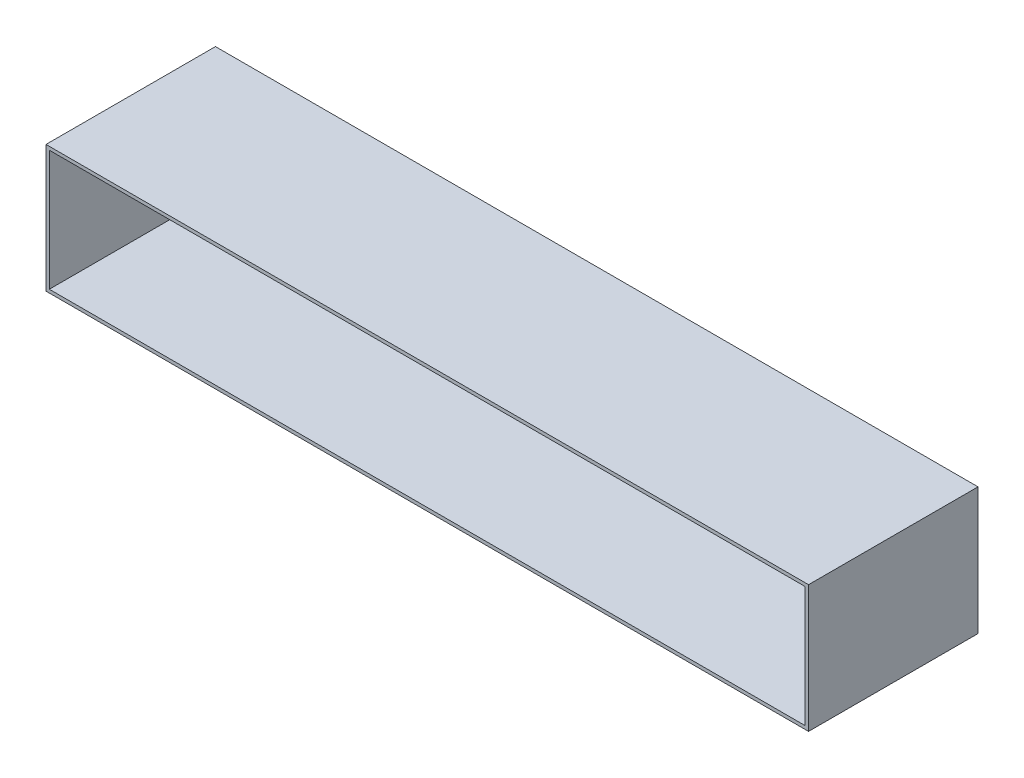
from build123d import *

# Parameters (mm, degrees)
SKETCH_1_W      = 457.2
SKETCH_1_H      = 76.2
SKETCH_1_W_2    = 453.2
SKETCH_1_H_2    = 72.2
EXTRUDE_1_DEPTH = 50.8


with BuildPart() as part:
    # Эскиз1 → Бобышка-Вытянуть1 (new body, symmetric)
    with BuildSketch(Plane.XY):
        Rectangle(SKETCH_1_W, SKETCH_1_H)
        Rectangle(SKETCH_1_W_2, SKETCH_1_H_2, mode=Mode.SUBTRACT)
    extrude(amount=EXTRUDE_1_DEPTH, both=True)


solid = part.part
